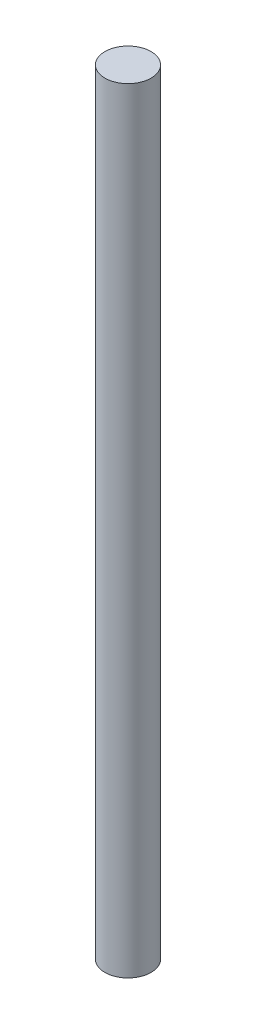
from build123d import *

# Parameters (mm, degrees)
SKETCH1_R           = 4.7625
BOSS_EXTRUDE1_DEPTH = 160


with BuildPart() as part:
    # Sketch1 → Boss-Extrude1 (new body)
    with BuildSketch(Plane(origin=(0, 0, 0), x_dir=(1, 0, 0), z_dir=(0, 1, 0))):
        Circle(SKETCH1_R)
    extrude(amount=BOSS_EXTRUDE1_DEPTH)


solid = part.part
